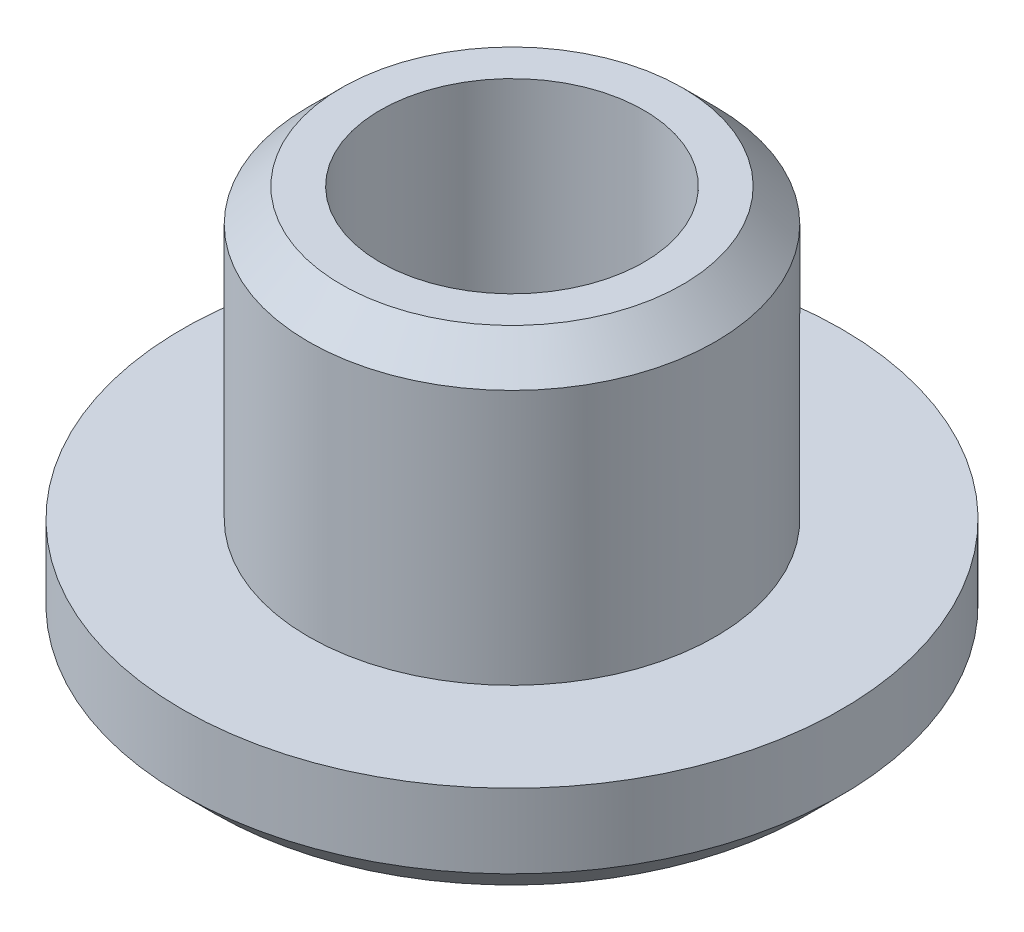
from build123d import *

# Parameters (mm, degrees)
CHANFREIN1_SIZE = 0.4


with BuildPart() as part:
    # Esquisse1 → Révolution1 (revolve)
    with BuildSketch(Plane.XY):
        Polygon((1.6, -1.131933067), (4, -1.131933067), (4, 0.168066933), (2.47, 0.168066933), (2.47, 3.668066933), (1.6, 3.668066933), align=None)
    revolve(axis=Axis((0, 4.72147651, 0), (0, -1, 0)))

    # Chanfrein1
    chanfrein1_edges = [part.edges().sort_by_distance(p)[0] for p in [
        (-4, -1.131933067, 0),
        (-2.47, 3.668066933, 0),
    ]]
    chamfer(chanfrein1_edges, length=CHANFREIN1_SIZE)


solid = part.part
